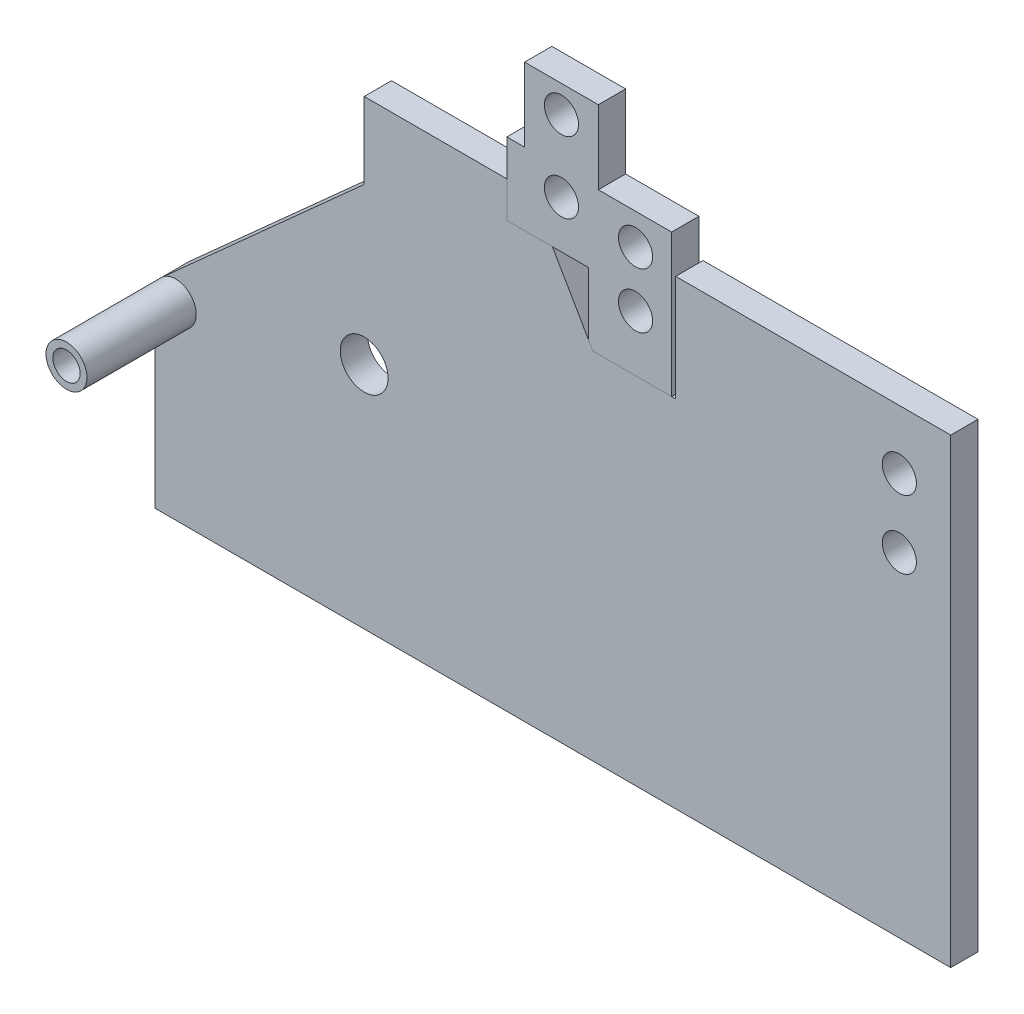
from build123d import *

# Parameters (mm, degrees)
SKETCH1_R           = 17.5
SKETCH1_R_2         = 10
BOSS_EXTRUDE1_DEPTH = 20
SKETCH2_R           = 15
SKETCH2_R_2         = 10
BOSS_EXTRUDE2_DEPTH = 80
BOSS_EXTRUDE6_DEPTH = 20
BOSS_EXTRUDE7_DEPTH = 20
SKETCH10_R          = 12.5
BOSS_EXTRUDE9_DEPTH = 20
SKETCH11_R          = 12.5
CUT_EXTRUDE1_DEPTH  = 20


with BuildPart() as part:
    # Sketch1 → Boss-Extrude1 (new body)
    with BuildSketch(Plane.XY):
        with BuildLine():
            Line((0, 138), (0, 0))
            Line((0, 0), (582.5, 0))
            Line((582.5, 0), (582.5, 51.183650965))
            Line((582.5, 51.183650965), (572.5, 51.183650965))
            Line((572.5, 51.183650965), (374.649400312, 86.070049839))
            Line((374.649400312, 86.070049839), (244.94, 310.733321399))
            ThreePointArc((244.94, 310.733321399), (200.912248971, 330.848790378), (153, 337.740187298))
            Line((153, 337.740187298), (153, 281.918848091))
            Line((153, 281.918848091), (4.984782256, 149.166710059))
            ThreePointArc((4.984782256, 149.166710059), (1.302769146, 144.114398329), (0, 138))
        make_face()
        with Locations((153, 167.740187298)):
            Circle(SKETCH1_R, mode=Mode.SUBTRACT)
        with Locations((15, 138)):
            Circle(SKETCH1_R_2, mode=Mode.SUBTRACT)
    extrude(amount=BOSS_EXTRUDE1_DEPTH)

    # Sketch2 → Boss-Extrude2 (add)
    with BuildSketch(Plane.XY.offset(20)):
        with Locations((15, 138)):
            Circle(SKETCH2_R)
        with Locations((15, 138)):
            Circle(SKETCH2_R_2, mode=Mode.SUBTRACT)
    extrude(amount=BOSS_EXTRUDE2_DEPTH)

    # Sketch4 → Boss-Extrude6 (add)
    with BuildSketch(Plane.XY.offset(20)):
        with BuildLine():
            Line((257.460495765, 337.740187298), (153, 337.740187298))
            ThreePointArc((153, 337.740187298), (200.912248971, 330.848790378), (244.94, 310.733321399))
            Line((244.94, 310.733321399), (374.649400312, 86.070049839))
            Line((374.649400312, 86.070049839), (426.173106487, 76.985030294))
            Line((426.173106487, 76.985030294), (290.842773548, 311.384042751))
            Line((290.842773548, 311.384042751), (257.460495765, 311.384042751))
            Line((257.460495765, 311.384042751), (257.460495765, 337.740187298))
        make_face()
    extrude(amount=-BOSS_EXTRUDE6_DEPTH)

    # Sketch9 → Boss-Extrude7 (add)
    with BuildSketch(Plane.XY.offset(20)):
        Polygon((582.5, 337.740187298), (582.5, 51.183650965), (572.5, 51.183650965), (522.5, 60), (426.173106487, 76.985030294), (320.509364462, 260), (381.119364462, 260), (381.119364462, 337.740187298), (525.48, 337.740187298), align=None)
    extrude(amount=-BOSS_EXTRUDE7_DEPTH)

    # Sketch11 → Cut-Extrude1 (cut)
    with BuildSketch(Plane(origin=(0, 0, 0), x_dir=(-1, 0, 0), z_dir=(0, 0, -1))):
        with Locations((-544.895661023, 294.516190979)):
            Circle(SKETCH11_R)
        with Locations((-544.895661023, 244.516190979)):
            Circle(SKETCH11_R)
    extrude(amount=-CUT_EXTRUDE1_DEPTH, mode=Mode.SUBTRACT)


with BuildPart() as body_2:
    # Sketch10 → Boss-Extrude9 (new body)
    with BuildSketch(Plane.XY.offset(20)):
        Polygon((270.460495765, 418.251615442), (270.460495765, 364.320187298), (317.180522157, 364.320187298), (324.460495765, 364.320187298), (324.460495765, 418.251615442), align=None)
        with Locations((297.460495765, 398.384042751)):
            Circle(SKETCH10_R, mode=Mode.SUBTRACT)
        Polygon((270.460495765, 364.320187298), (257.460495765, 364.320187298), (257.460495765, 337.740187298), (257.460495765, 311.384042751), (290.842773548, 311.384042751), (317.180522157, 311.384042751), (317.180522157, 321.223855452), (317.180522157, 364.320187298), align=None)
        with Locations((297.460495765, 346.134042751)):
            Circle(SKETCH10_R, mode=Mode.SUBTRACT)
        Polygon((324.460495765, 364.320187298), (317.180522157, 364.320187298), (317.180522157, 321.223855452), (347.650508961, 321.223855452), (378.120495765, 321.223855452), (378.120495765, 364.320187298), align=None)
        with Locations((351.710495765, 341.56)):
            Circle(SKETCH10_R, mode=Mode.SUBTRACT)
        Polygon((347.650508961, 321.223855452), (317.180522157, 321.223855452), (317.180522157, 311.384042751), (317.180522157, 265.765724002), (320.509364462, 260), (378.120495765, 260), (378.120495765, 321.223855452), align=None)
        with Locations((351.710495765, 301)):
            Circle(SKETCH10_R, mode=Mode.SUBTRACT)
    extrude(amount=-BOSS_EXTRUDE9_DEPTH)


solid = Compound([part.part, body_2.part])
